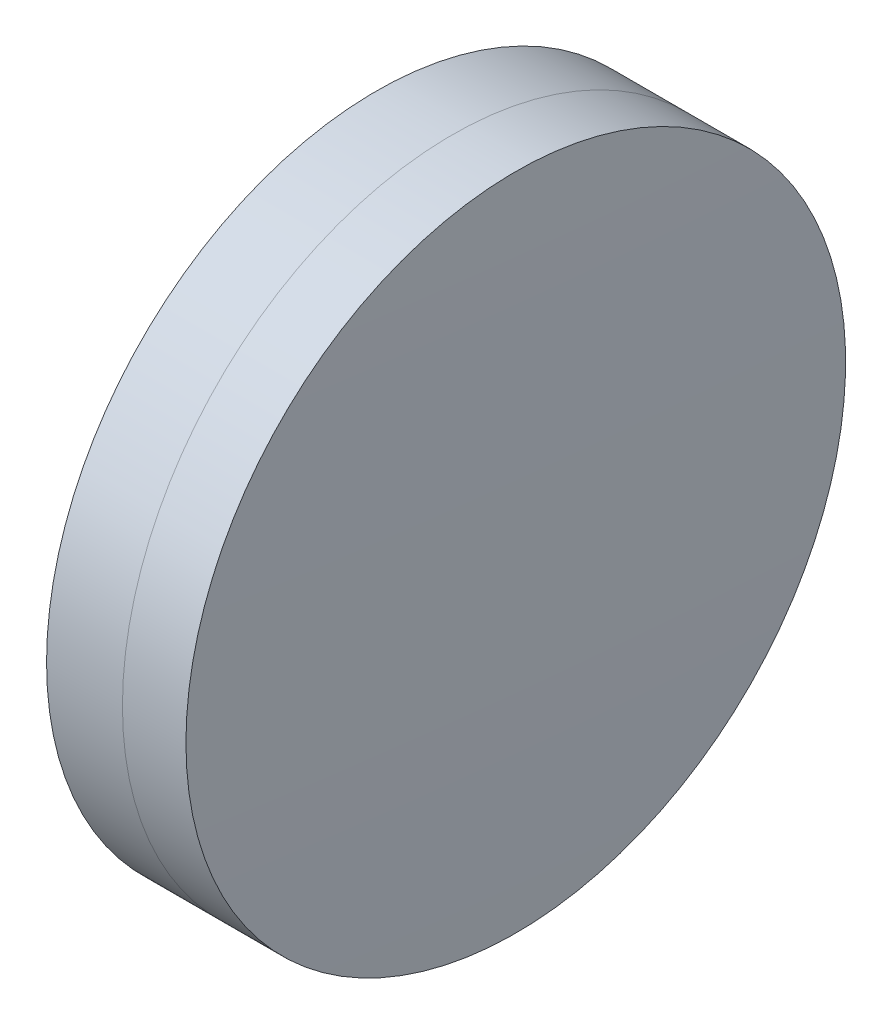
from build123d import *


with BuildPart() as part:
    # 草图1 one side → 旋转1 (revolve)
    with BuildSketch(Plane(origin=(0, 0, 0), x_dir=(1, 0, 0), z_dir=(0, 1, 0)), mode=Mode.PRIVATE) as revolve_1_sk:
        with BuildLine():
            ThreePointArc((314.488336807, 12.7), (314.121715105, 6.354703233), (313.999447543, 0))
            Line((313.999447543, 0), (317.999447543, 0))
            ThreePointArc((317.999447543, 0), (317.851996355, 6.356836784), (317.409959959, 12.7))
            Line((317.409959959, 12.7), (314.488336807, 12.7))
        make_face()
    revolve(revolve_1_sk.sketch.rotate(Axis((235.807450691, 0, 0), (1, 0, 0)), 180), axis=Axis((235.807450691, 0, 0), (1, 0, 0)))  # turned: the seam where the file's is


with BuildPart() as body_2:
    # 草图2 one side → 旋转3 (revolve)
    with BuildSketch(Plane(origin=(0, 0, 0), x_dir=(1, 0, 0), z_dir=(0, 1, 0)), mode=Mode.PRIVATE) as revolve_3_sk:
        with BuildLine():
            Line((319.854748101, 12.7), (317.409959959, 12.7))
            ThreePointArc((317.409959959, 12.7), (317.851996355, 6.356836784), (317.999447543, 0))
            Line((317.999447543, 0), (319.999447543, 0))
            ThreePointArc((319.999447543, 0), (319.963271509, 6.350412151), (319.854748101, 12.7))
        make_face()
    revolve(revolve_3_sk.sketch.rotate(Axis((-0.551919993, 0, 0), (1, 0, 0)), 180), axis=Axis((-0.551919993, 0, 0), (1, 0, 0)))  # turned: the seam where the file's is


solid = Compound([part.part, body_2.part])
